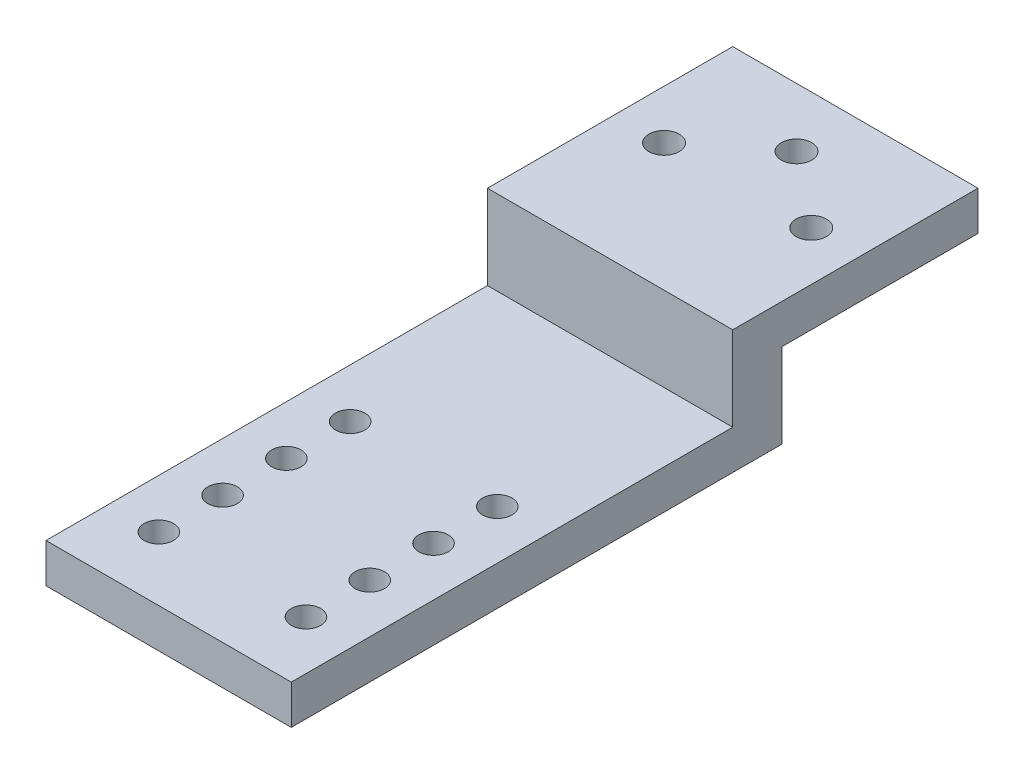
from build123d import *

# Parameters (mm, degrees)
SKETCH_1_W          = 25
SKETCH_1_H          = 70
SKETCH_1_R          = 1.55
SKETCH_1_R_2        = 1.5
EXTRUDE_1_DEPTH     = 4
SKETCH_2_W          = 25
SKETCH_2_H          = 25
SKETCH_2_R          = 1.55
EXTRUDE_2_DEPTH     = 8.6
SKETCH_3_W          = 25
SKETCH_3_H          = 20
SKETCH_3_R          = 1.55
CUT_EXTRUDE_1_DEPTH = 8.6


with BuildPart() as part:
    # Эскиз1 → Бобышка-Вытянуть1 (new body)
    with BuildSketch(Plane(origin=(0, 0, 0), x_dir=(1, 0, 0), z_dir=(0, 1, 0))):
        with Locations((0, 13.852233677)):
            Rectangle(SKETCH_1_W, SKETCH_1_H)
        with Locations((-7.5, 36.852233677)):
            Circle(SKETCH_1_R, mode=Mode.SUBTRACT)
        with Locations((7.5, 36.852233677)):
            Circle(SKETCH_1_R, mode=Mode.SUBTRACT)
        with Locations((-7.5, -14.647766323)):
            Circle(SKETCH_1_R_2, mode=Mode.SUBTRACT)
        with Locations((7.5, -14.647766323)):
            Circle(SKETCH_1_R_2, mode=Mode.SUBTRACT)
        with Locations((-7.5, -8.147766323)):
            Circle(SKETCH_1_R_2, mode=Mode.SUBTRACT)
        with Locations((7.5, -8.147766323)):
            Circle(SKETCH_1_R_2, mode=Mode.SUBTRACT)
        with Locations((-7.5, -1.647766323)):
            Circle(SKETCH_1_R_2, mode=Mode.SUBTRACT)
        with Locations((7.5, -1.647766323)):
            Circle(SKETCH_1_R_2, mode=Mode.SUBTRACT)
        with Locations((-7.5, 4.852233677)):
            Circle(SKETCH_1_R_2, mode=Mode.SUBTRACT)
        with Locations((7.5, 4.852233677)):
            Circle(SKETCH_1_R_2, mode=Mode.SUBTRACT)
        with Locations((0, 42.852233677)):
            Circle(SKETCH_1_R, mode=Mode.SUBTRACT)
    extrude(amount=EXTRUDE_1_DEPTH)

    # Эскиз2 → Бобышка-Вытянуть2 (add)
    with BuildSketch(Plane(origin=(0, 4, 0), x_dir=(1, 0, 0), z_dir=(0, 1, 0))):
        with Locations((0, 36.352233677)):
            Rectangle(SKETCH_2_W, SKETCH_2_H)
        with Locations((0, 42.852233677)):
            Circle(SKETCH_2_R, mode=Mode.SUBTRACT)
        with Locations((7.5, 36.852233677)):
            Circle(SKETCH_2_R, mode=Mode.SUBTRACT)
        with Locations((-7.5, 36.852233677)):
            Circle(SKETCH_2_R, mode=Mode.SUBTRACT)
    extrude(amount=EXTRUDE_2_DEPTH)

    # Эскиз3 → Вырез-Вытянуть1 (cut)
    with BuildSketch(Plane.XZ):
        with Locations((0, -38.852233677)):
            Rectangle(SKETCH_3_W, SKETCH_3_H)
        with Locations((-7.5, -36.852233677)):
            Circle(SKETCH_3_R, mode=Mode.SUBTRACT)
        with Locations((7.5, -36.852233677)):
            Circle(SKETCH_3_R, mode=Mode.SUBTRACT)
        with Locations((0, -42.852233677)):
            Circle(SKETCH_3_R, mode=Mode.SUBTRACT)
    extrude(amount=-CUT_EXTRUDE_1_DEPTH, mode=Mode.SUBTRACT)


solid = part.part
